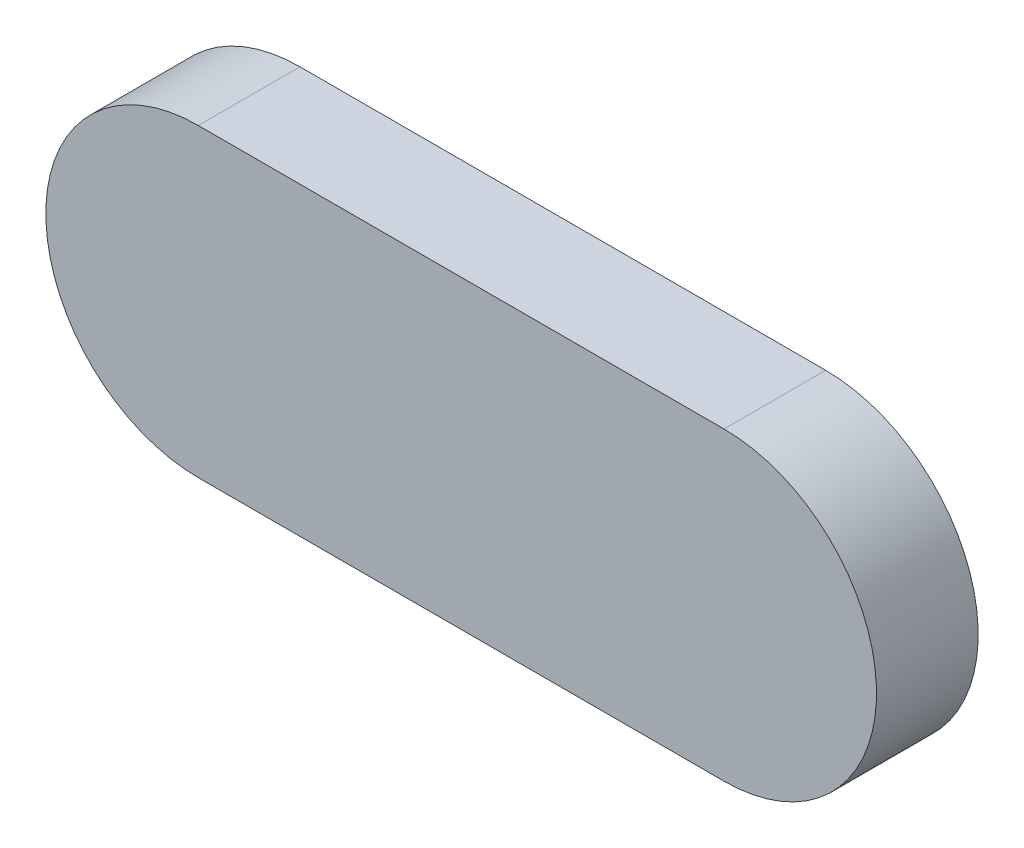
from build123d import *

# Parameters (mm, degrees)
EXTRUDE_1_DEPTH = 2.5


with BuildPart() as part:
    # 草图1 → 凸台-拉伸1 (new body, symmetric)
    with BuildSketch(Plane.XY):
        with BuildLine():
            Line((12.925, 7.5), (-12.925, 7.5))
            ThreePointArc((-12.925, 7.5), (-20.425, 0), (-12.925, -7.5))
            Line((-12.925, -7.5), (12.925, -7.5))
            ThreePointArc((12.925, -7.5), (20.425, 0), (12.925, 7.5))
        make_face()
    extrude(amount=EXTRUDE_1_DEPTH, both=True)


solid = part.part
